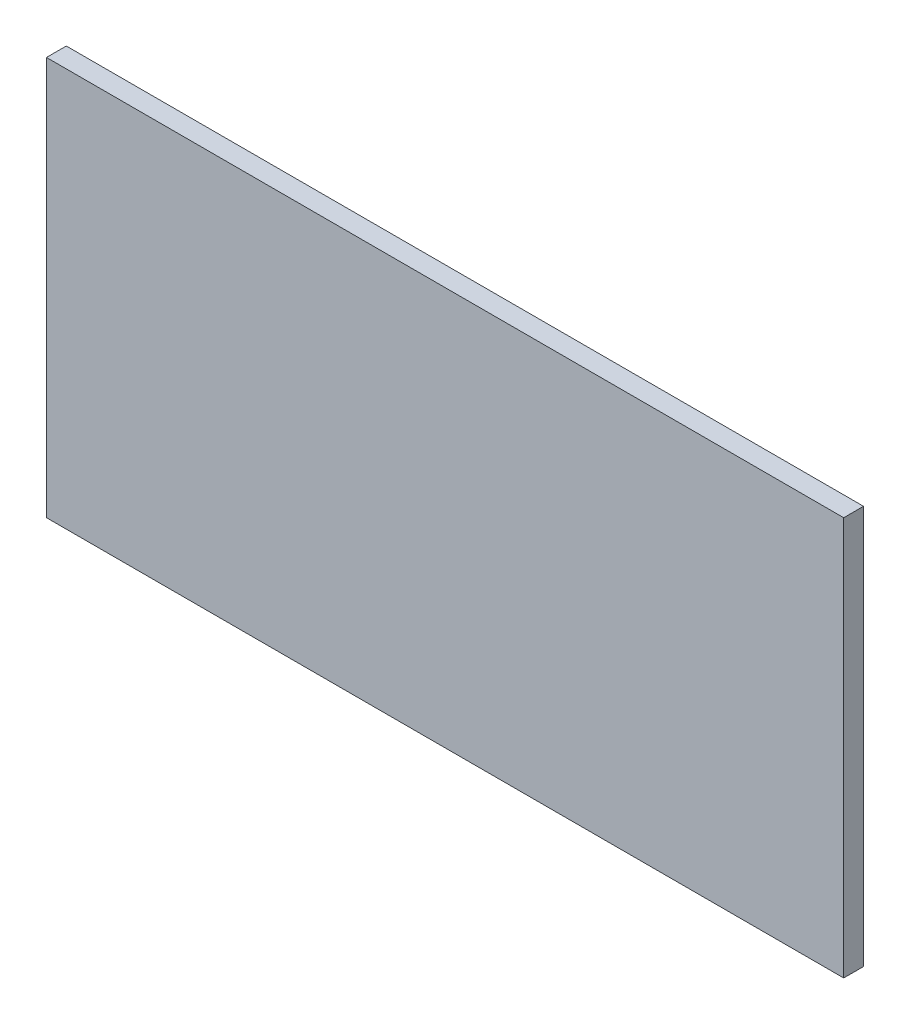
from build123d import *

# Parameters (mm, degrees)
SKETCH1_W           = 181
SKETCH1_H           = 90.5
BOSS_EXTRUDE1_DEPTH = 2.25


with BuildPart() as part:
    # Sketch1 → Boss-Extrude1 (new body, symmetric)
    with BuildSketch(Plane.XY):
        with Locations((0, 45.25)):
            Rectangle(SKETCH1_W, SKETCH1_H)
    extrude(amount=BOSS_EXTRUDE1_DEPTH, both=True)


solid = part.part
